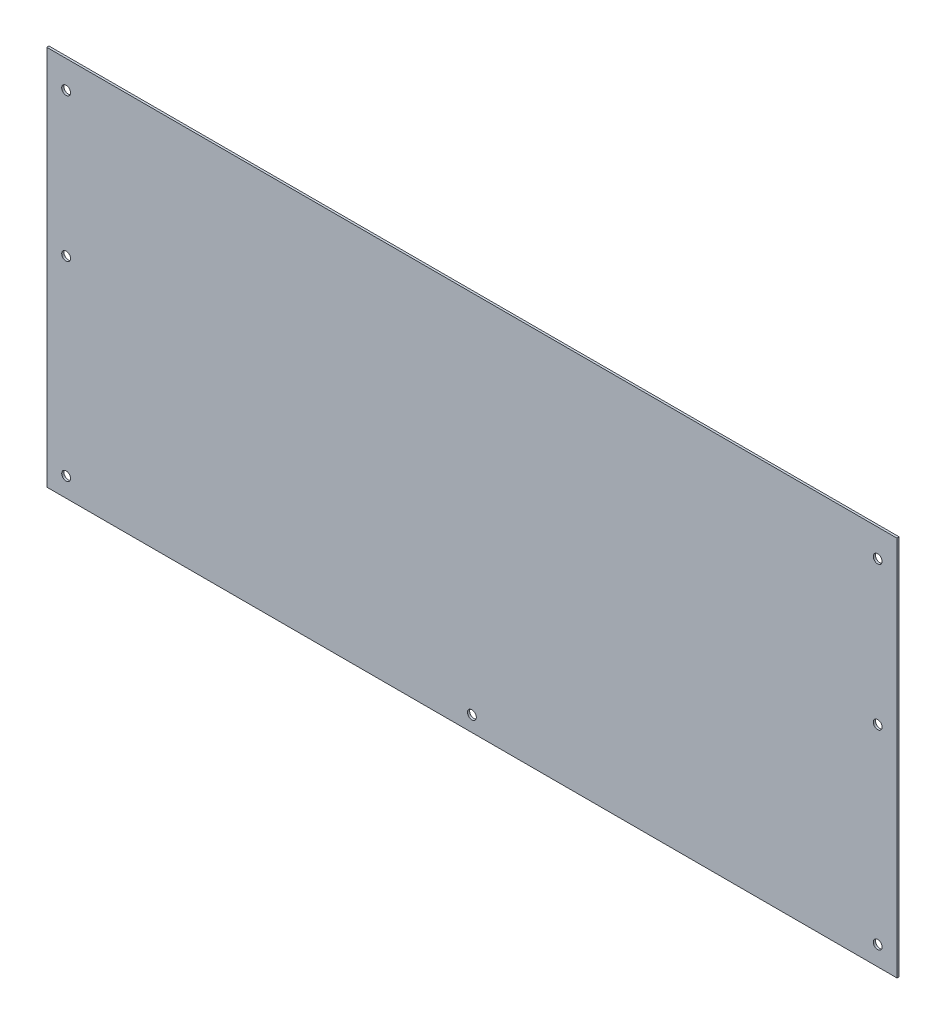
from build123d import *

# Parameters (mm, degrees)
SKETCH1_W           = 770
SKETCH1_H           = 345
SKETCH1_R           = 4
BOSS_EXTRUDE1_DEPTH = 2


with BuildPart() as part:
    # Sketch1 → Boss-Extrude1 (new body)
    with BuildSketch(Plane.XY):
        with Locations((385, 172.5)):
            Rectangle(SKETCH1_W, SKETCH1_H)
        with Locations((17.5, 320)):
            Circle(SKETCH1_R, mode=Mode.SUBTRACT)
        with Locations((17.5, 17.5)):
            Circle(SKETCH1_R, mode=Mode.SUBTRACT)
        with Locations(Location((752.5, 17.5, 0), (0, 0, 180))):  # turned: the seam where the file's is
            Circle(SKETCH1_R, mode=Mode.SUBTRACT)
        with Locations((385, 13.902040844)):
            Circle(SKETCH1_R, mode=Mode.SUBTRACT)
        with Locations((17.5, 190)):
            Circle(SKETCH1_R, mode=Mode.SUBTRACT)
        with Locations(Location((752.5, 190, 0), (0, 0, 180))):  # turned: the seam where the file's is
            Circle(SKETCH1_R, mode=Mode.SUBTRACT)
        with Locations(Location((752.5, 320, 0), (0, 0, 180))):  # turned: the seam where the file's is
            Circle(SKETCH1_R, mode=Mode.SUBTRACT)
    extrude(amount=BOSS_EXTRUDE1_DEPTH)


solid = part.part
